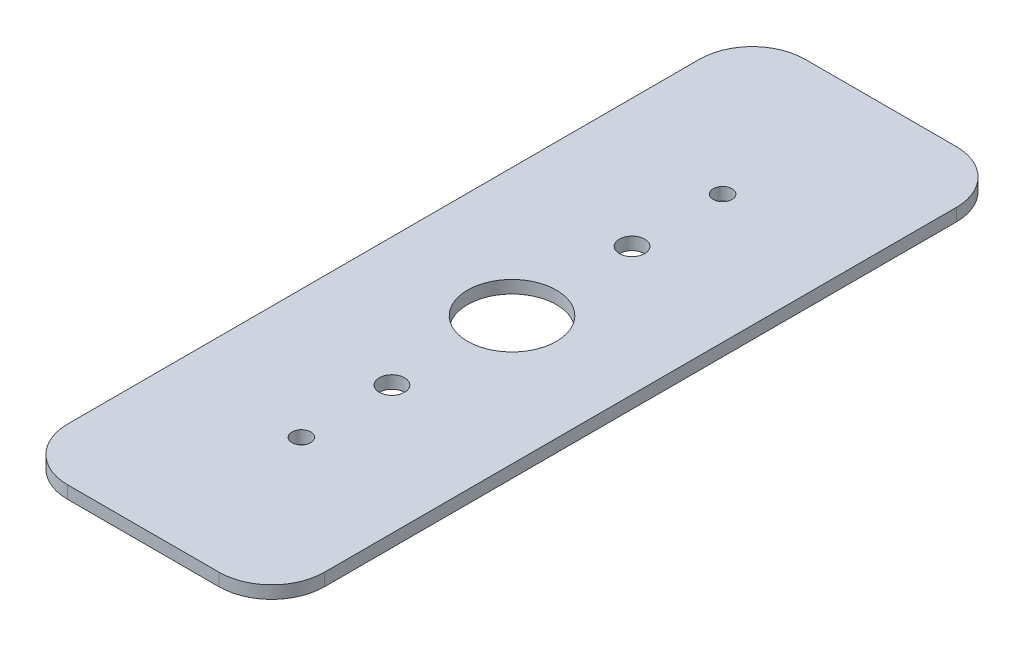
from build123d import *

# Parameters (mm, degrees)
SKETCH1_W               = 30.95625
SKETCH1_H               = 88.9
BOSS_EXTRUDE1_DEPTH     = 1.524
FILLET1_R               = 6.35
SKETCH6_R               = 1.524
CUT_EXTRUDE1_DEPTH      = 2.524
F_4_40_TAPPED_HOLE1_D   = 2.2606
F_1_2_13_TAPPED_HOLE1_D = 10.71626


with BuildPart() as part:
    # Sketch1 → Boss-Extrude1 (new body)
    with BuildSketch(Plane(origin=(0, 0, 0), x_dir=(1, 0, 0), z_dir=(0, 1, 0))):
        Rectangle(SKETCH1_W, SKETCH1_H)
    extrude(amount=BOSS_EXTRUDE1_DEPTH)

    # Fillet1
    fillet1_edges = [part.edges().sort_by_distance(p)[0] for p in [
        (15.478125, 0.762, -44.45),
        (15.478125, 0.762, 44.45),
        (-15.478125, 0.762, 44.45),
        (-15.478125, 0.762, -44.45),
    ]]
    fillet(fillet1_edges, radius=FILLET1_R)

    # Sketch6 → Cut-Extrude1 (cut, through all)
    with BuildSketch(Plane.XZ):
        with Locations((0, 14.478)):
            Circle(SKETCH6_R)
        with Locations((0, -14.478)):
            Circle(SKETCH6_R)
    extrude(amount=-CUT_EXTRUDE1_DEPTH, mode=Mode.SUBTRACT)

    # #4-40 Tapped Hole1 (through all)
    with Locations(Plane(origin=(0, 1.524, 0), x_dir=(-1, 0, 0), z_dir=(0, 1, 0))):
        with Locations((0, 25.4), (0, -25.4)):
            Hole(F_4_40_TAPPED_HOLE1_D / 2)

    # 1/2-13 Tapped Hole1 (through all)
    with Locations(Plane(origin=(0, 1.524, 0), x_dir=(-1, 0, 0), z_dir=(0, 1, 0))):
        with Locations((0, 0)):
            Hole(F_1_2_13_TAPPED_HOLE1_D / 2)


solid = part.part
